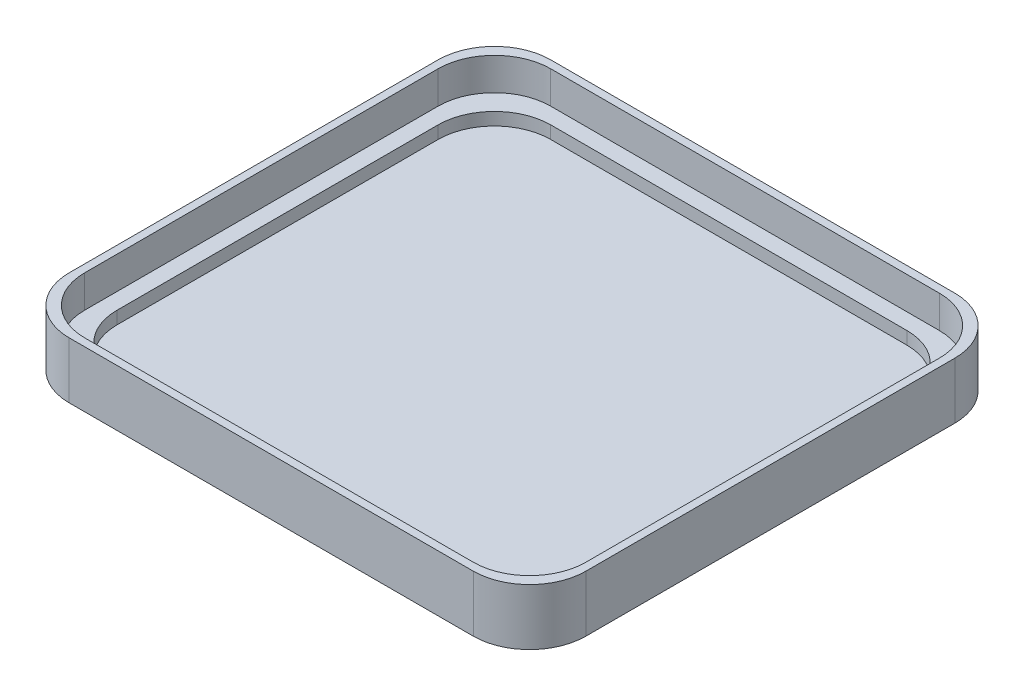
from build123d import *

# Parameters (mm, degrees)
SKETCH1_W           = 93.218
SKETCH1_H           = 86.868
BOSS_EXTRUDE1_DEPTH = 10.16
SKETCH2_W           = 90.424
SKETCH2_H           = 84.074
CUT_EXTRUDE1_DEPTH  = 5.842
SKETCH3_W           = 84.582
SKETCH3_H           = 78.232
CUT_EXTRUDE2_DEPTH  = 2.286
FILLET1_R           = 10.16


with BuildPart() as part:
    # Sketch1 → Boss-Extrude1 (new body)
    with BuildSketch(Plane(origin=(0, 0, 0), x_dir=(1, 0, 0), z_dir=(0, 1, 0))):
        Rectangle(SKETCH1_W, SKETCH1_H)
    extrude(amount=BOSS_EXTRUDE1_DEPTH)

    # Sketch2 → Cut-Extrude1 (cut)
    with BuildSketch(Plane(origin=(0, 10.16, 0), x_dir=(1, 0, 0), z_dir=(0, 1, 0))):
        Rectangle(SKETCH2_W, SKETCH2_H)
    extrude(amount=-CUT_EXTRUDE1_DEPTH, mode=Mode.SUBTRACT)

    # Sketch3 → Cut-Extrude2 (cut)
    with BuildSketch(Plane(origin=(0, 4.318, 0), x_dir=(1, 0, 0), z_dir=(0, 1, 0))):
        Rectangle(SKETCH3_W, SKETCH3_H)
    extrude(amount=-CUT_EXTRUDE2_DEPTH, mode=Mode.SUBTRACT)

    # Fillet1
    fillet1_edges = [part.edges().sort_by_distance(p)[0] for p in [
        (45.212, 7.239, -42.037),
        (45.212, 7.239, 42.037),
        (-45.212, 7.239, 42.037),
        (-45.212, 7.239, -42.037),
        (42.291, 3.175, -39.116),
        (42.291, 3.175, 39.116),
        (-42.291, 3.175, 39.116),
        (-42.291, 3.175, -39.116),
        (46.609, 5.08, 43.434),
        (-46.609, 5.08, 43.434),
        (-46.609, 5.08, -43.434),
        (46.609, 5.08, -43.434),
    ]]
    fillet(fillet1_edges, radius=FILLET1_R)


solid = part.part
